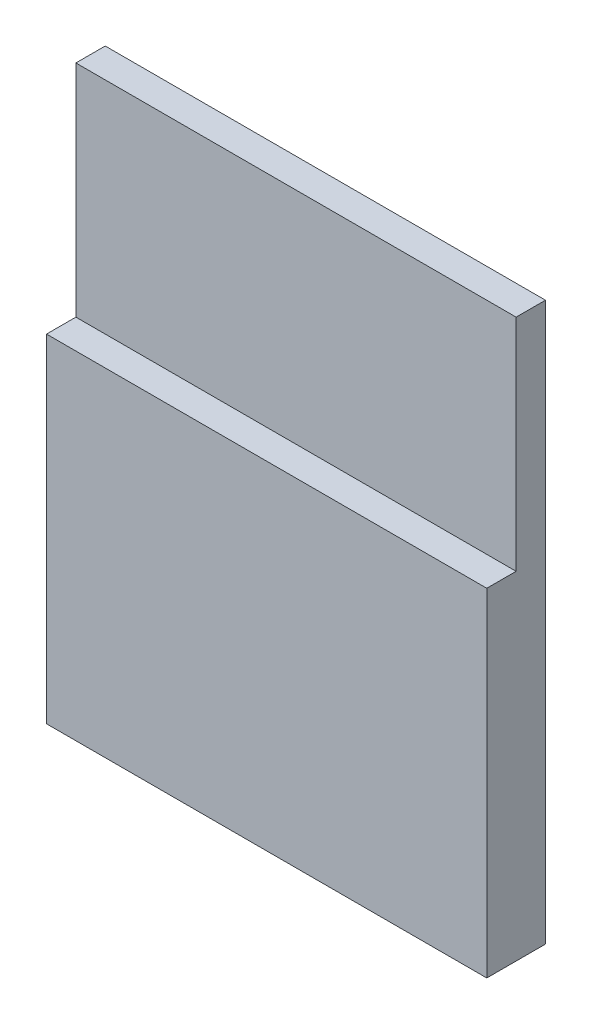
from build123d import *

# Parameters (mm, degrees)
SKETCH_1_W      = 30
SKETCH_1_H      = 38
EXTRUDE_1_DEPTH = 2
SKETCH_2_W      = 30
SKETCH_2_H      = 23
EXTRUDE_2_DEPTH = 2


with BuildPart() as part:
    # 草图1 → 凸台-拉伸1 (new body)
    with BuildSketch(Plane.XY):
        with Locations((-15, 19)):
            Rectangle(SKETCH_1_W, SKETCH_1_H)
    extrude(amount=EXTRUDE_1_DEPTH)

    # 草图2 → 凸台-拉伸2 (add)
    with BuildSketch(Plane.XY.offset(2)):
        with Locations((-15, 11.5)):
            Rectangle(SKETCH_2_W, SKETCH_2_H)
    extrude(amount=EXTRUDE_2_DEPTH)


solid = part.part
